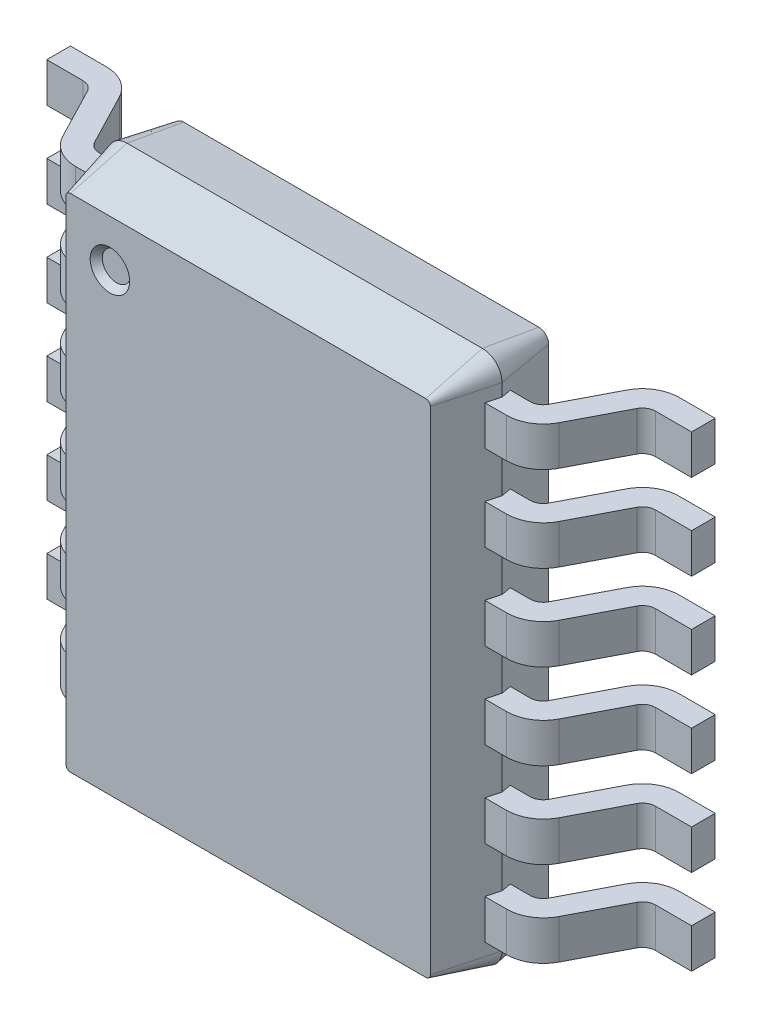
from build123d import *

# Parameters (mm, degrees)
EXTRUDE_START             = 0.67
EXTRUDE_1_DEPTH           = 0.43
EXTRUDE_1_TAPER           = 15
EXTRUDE_1_OTHER_WAY_DEPTH = 0.43
EXTRUDE_1_OTHER_WAY_TAPER = 10
EXTRUDE_START_2           = 1.625
EXTRUDE_2_DEPTH           = 0.15
PATTERN_LINEAR_1_COUNT    = 6
PATTERN_LINEAR_1_PITCH    = 0.65
SKETCH_2_R                = 0.15
CUT_EXTRUDE_3_DEPTH       = 0.05
CUT_EXTRUDE_3_TAPER       = 40


with BuildPart() as part:
    # Эскиз1 → Вытянуть1 (new body)
    with BuildSketch(Plane.XY.offset(EXTRUDE_START)):
        with BuildLine():
            ThreePointArc((-1.35, 2.02), (-1.456066017, 1.976066017), (-1.5, 1.87))
            Line((-1.5, 1.87), (-1.5, -1.87))
            ThreePointArc((-1.5, -1.87), (-1.456066017, -1.976066017), (-1.35, -2.02))
            Line((-1.35, -2.02), (1.35, -2.02))
            ThreePointArc((1.35, -2.02), (1.456066017, -1.976066017), (1.5, -1.87))
            Line((1.5, -1.87), (1.5, 1.87))
            ThreePointArc((1.5, 1.87), (1.456066017, 1.976066017), (1.35, 2.02))
            Line((1.35, 2.02), (-1.35, 2.02))
        make_face()
    extrude(amount=EXTRUDE_1_DEPTH, taper=EXTRUDE_1_TAPER)

    # Эскиз1 → Вытянуть1 other way (add)
    with BuildSketch(Plane.XY.offset(EXTRUDE_START)):
        with BuildLine():
            ThreePointArc((-1.35, 2.02), (-1.456066017, 1.976066017), (-1.5, 1.87))
            Line((-1.5, 1.87), (-1.5, -1.87))
            ThreePointArc((-1.5, -1.87), (-1.456066017, -1.976066017), (-1.35, -2.02))
            Line((-1.35, -2.02), (1.35, -2.02))
            ThreePointArc((1.35, -2.02), (1.456066017, -1.976066017), (1.5, -1.87))
            Line((1.5, -1.87), (1.5, 1.87))
            ThreePointArc((1.5, 1.87), (1.456066017, 1.976066017), (1.35, 2.02))
            Line((1.35, 2.02), (-1.35, 2.02))
        make_face()
    extrude(amount=-EXTRUDE_1_OTHER_WAY_DEPTH, taper=EXTRUDE_1_OTHER_WAY_TAPER)

    # Эскиз3 → Вытянуть2 (add, symmetric)
    with BuildSketch(Plane(origin=(0, 0, 0), x_dir=(1, 0, 0), z_dir=(0, 1, 0)).offset(EXTRUDE_START_2)):
        with BuildLine():
            Line((-1.375410794, -0.594), (-1.637012894, -0.594))
            ThreePointArc((-1.637012894, -0.594), (-1.688929581, -0.579467289), (-1.725756465, -0.540093151))
            Line((-1.725756465, -0.540093151), (-1.927881899, -0.150939177))
            ThreePointArc((-1.927881899, -0.150939177), (-2.030997173, -0.04069159), (-2.176363898, 0))
            Line((-2.176363898, 0), (-2.45, 0))
            Line((-2.45, 0), (-2.45, -0.18))
            Line((-2.45, -0.18), (-2.176363898, -0.18))
            ThreePointArc((-2.176363898, -0.18), (-2.124447211, -0.194532711), (-2.087620327, -0.233906849))
            Line((-2.087620327, -0.233906849), (-1.885911421, -0.622258877))
            ThreePointArc((-1.885911421, -0.622258877), (-1.782796147, -0.732506464), (-1.637429422, -0.773198054))
            Line((-1.637429422, -0.773198054), (-1.375410794, -0.773198054))
            Line((-1.375410794, -0.773198054), (-1.375410794, -0.594))
        make_face()
        with BuildLine():
            Line((2.087620327, -0.233906849), (1.885911421, -0.622258877))
            ThreePointArc((1.885911421, -0.622258877), (1.782796147, -0.732506464), (1.637429422, -0.773198054))
            Line((1.637429422, -0.773198054), (1.375410794, -0.773198054))
            Line((1.375410794, -0.773198054), (1.375410794, -0.594))
            Line((1.375410794, -0.594), (1.637012894, -0.594))
            ThreePointArc((1.637012894, -0.594), (1.688929581, -0.579467289), (1.725756465, -0.540093151))
            Line((1.725756465, -0.540093151), (1.927881899, -0.150939177))
            ThreePointArc((1.927881899, -0.150939177), (2.030997173, -0.04069159), (2.176363898, 0))
            Line((2.176363898, 0), (2.45, 0))
            Line((2.45, 0), (2.45, -0.18))
            Line((2.45, -0.18), (2.176363898, -0.18))
            ThreePointArc((2.176363898, -0.18), (2.124447211, -0.194532711), (2.087620327, -0.233906849))
        make_face()
    extrude_2 = extrude(amount=EXTRUDE_2_DEPTH, both=True)

    # Линейный массив1: Вытянуть2 ×6
    with Locations(*[(0, -i * PATTERN_LINEAR_1_PITCH, 0) for i in range(1, PATTERN_LINEAR_1_COUNT)]):
        add(extrude_2)

    # Эскиз2 → Вытянуть3 (cut)
    with BuildSketch(Plane.XY.offset(1.1)):
        with Locations((-1.05, 1.55)):
            Circle(SKETCH_2_R)
    extrude(amount=-CUT_EXTRUDE_3_DEPTH, taper=CUT_EXTRUDE_3_TAPER, mode=Mode.SUBTRACT)


solid = part.part
